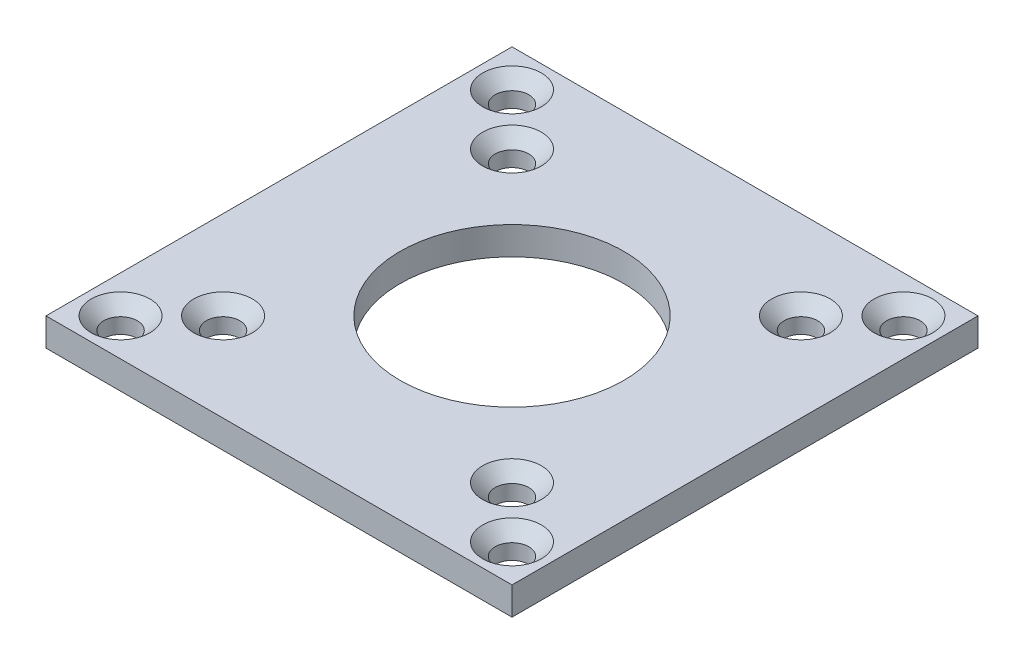
from build123d import *

# Parameters (mm, degrees)
PLATE_W                                        = 50
PLATE_H                                        = 50
BOSS_EXTRUDE1_DEPTH                            = 3
CSK_FOR_M3_OVAL_HEAD_MACHINE_SCREW1_AT_2_COUNT = 2
CSK_FOR_M3_OVAL_HEAD_MACHINE_SCREW1_AT_2_PITCH = 42
CSK_FOR_M3_OVAL_HEAD_MACHINE_SCREW1_AT_3_COUNT = 2
CSK_FOR_M3_OVAL_HEAD_MACHINE_SCREW1_AT_3_PITCH = 59.39696962
CSK_FOR_M3_OVAL_HEAD_MACHINE_SCREW1_AT_4_COUNT = 2
CSK_FOR_M3_OVAL_HEAD_MACHINE_SCREW1_AT_4_PITCH = 42
F_24_0_24_DIAMETER_HOLE1_D                     = 24
F_24_0_24_DIAMETER_HOLE1_ON_FACE_2_D           = 24
F_24_0_24_DIAMETER_HOLE1_ON_FACE_3_D           = 24
CSK_FOR_M3_OVAL_HEAD_MACHINE_SCREW2_AT_2_COUNT = 2
CSK_FOR_M3_OVAL_HEAD_MACHINE_SCREW2_AT_2_PITCH = 31
CSK_FOR_M3_OVAL_HEAD_MACHINE_SCREW2_AT_3_COUNT = 2
CSK_FOR_M3_OVAL_HEAD_MACHINE_SCREW2_AT_3_PITCH = 43.840620434
CSK_FOR_M3_OVAL_HEAD_MACHINE_SCREW2_AT_4_COUNT = 2
CSK_FOR_M3_OVAL_HEAD_MACHINE_SCREW2_AT_4_PITCH = 31


with BuildPart() as part:
    # Plate → Boss-Extrude1 (new body)
    with BuildSketch(Plane(origin=(0, 0, 0), x_dir=(1, 0, 0), z_dir=(0, 1, 0))):
        Rectangle(PLATE_W, PLATE_H)
    extrude(amount=BOSS_EXTRUDE1_DEPTH)

    # Sketch3 → CSK for M3 Oval Head Machine Screw1 (revolve, cut)
    with BuildSketch(Plane(origin=(-21, 3, 21), x_dir=(0, 0, 1), z_dir=(1, 0, 0))):
        Polygon((0, 0), (0, 3), (1.8, 3), (1.8, 1.35), (3.15, 0), align=None)
    csk_for_m3_oval_head_machine_screw1 = revolve(axis=Axis((-21, 9.35, 21), (0, -1, 0)), mode=Mode.SUBTRACT)

    # CSK for M3 Oval Head Machine Screw1 at 2: CSK for M3 Oval Head Machine Screw1 ×2
    with Locations(*[(0, 0, -i * CSK_FOR_M3_OVAL_HEAD_MACHINE_SCREW1_AT_2_PITCH) for i in range(1, CSK_FOR_M3_OVAL_HEAD_MACHINE_SCREW1_AT_2_COUNT)]):
        add(csk_for_m3_oval_head_machine_screw1, mode=Mode.SUBTRACT)

    # CSK for M3 Oval Head Machine Screw1 at 3: CSK for M3 Oval Head Machine Screw1 ×2
    with Locations(*[Vector(0.707106781, 0, -0.707106781) * (i * CSK_FOR_M3_OVAL_HEAD_MACHINE_SCREW1_AT_3_PITCH) for i in range(1, CSK_FOR_M3_OVAL_HEAD_MACHINE_SCREW1_AT_3_COUNT)]):
        add(csk_for_m3_oval_head_machine_screw1, mode=Mode.SUBTRACT)

    # CSK for M3 Oval Head Machine Screw1 at 4: CSK for M3 Oval Head Machine Screw1 ×2
    with Locations(*[(i * CSK_FOR_M3_OVAL_HEAD_MACHINE_SCREW1_AT_4_PITCH, 0, 0) for i in range(1, CSK_FOR_M3_OVAL_HEAD_MACHINE_SCREW1_AT_4_COUNT)]):
        add(csk_for_m3_oval_head_machine_screw1, mode=Mode.SUBTRACT)

    # Ø24.0 (24) Diameter Hole1 (through all)
    with Locations(Plane.ZX.offset(3)):
        with Locations((0, 0)):
            Hole(F_24_0_24_DIAMETER_HOLE1_D / 2)

    # Ø24.0 (24) Diameter Hole1 on face 2 (through all)
    with Locations(Plane(origin=(0, 0, 0), x_dir=(0, 0, -1), z_dir=(0, -1, 0))):
        with Locations((0, 0)):
            Hole(F_24_0_24_DIAMETER_HOLE1_ON_FACE_2_D / 2)

    # Ø24.0 (24) Diameter Hole1 on face 3 (through all)
    with Locations(Plane(origin=(-62.061079299, -166.048748064, 0), x_dir=(0, 0, 1), z_dir=(0, 1, 0))):
        with Locations((0, 0)):
            Hole(F_24_0_24_DIAMETER_HOLE1_ON_FACE_3_D / 2)

    # Sketch6 → CSK for M3 Oval Head Machine Screw2 (revolve, cut)
    with BuildSketch(Plane(origin=(-15.5, 3, -15.5), x_dir=(0, 0, 1), z_dir=(1, 0, 0))):
        Polygon((0, 0), (0, 3), (1.8, 3), (1.8, 1.35), (3.15, 0), align=None)
    csk_for_m3_oval_head_machine_screw2 = revolve(axis=Axis((-15.5, 9.35, -15.5), (0, -1, 0)), mode=Mode.SUBTRACT)

    # CSK for M3 Oval Head Machine Screw2 at 2: CSK for M3 Oval Head Machine Screw2 ×2
    with Locations(*[(i * CSK_FOR_M3_OVAL_HEAD_MACHINE_SCREW2_AT_2_PITCH, 0, 0) for i in range(1, CSK_FOR_M3_OVAL_HEAD_MACHINE_SCREW2_AT_2_COUNT)]):
        add(csk_for_m3_oval_head_machine_screw2, mode=Mode.SUBTRACT)

    # CSK for M3 Oval Head Machine Screw2 at 3: CSK for M3 Oval Head Machine Screw2 ×2
    with Locations(*[Vector(0.707106781, 0, 0.707106781) * (i * CSK_FOR_M3_OVAL_HEAD_MACHINE_SCREW2_AT_3_PITCH) for i in range(1, CSK_FOR_M3_OVAL_HEAD_MACHINE_SCREW2_AT_3_COUNT)]):
        add(csk_for_m3_oval_head_machine_screw2, mode=Mode.SUBTRACT)

    # CSK for M3 Oval Head Machine Screw2 at 4: CSK for M3 Oval Head Machine Screw2 ×2
    with Locations(*[(0, 0, i * CSK_FOR_M3_OVAL_HEAD_MACHINE_SCREW2_AT_4_PITCH) for i in range(1, CSK_FOR_M3_OVAL_HEAD_MACHINE_SCREW2_AT_4_COUNT)]):
        add(csk_for_m3_oval_head_machine_screw2, mode=Mode.SUBTRACT)


solid = part.part
